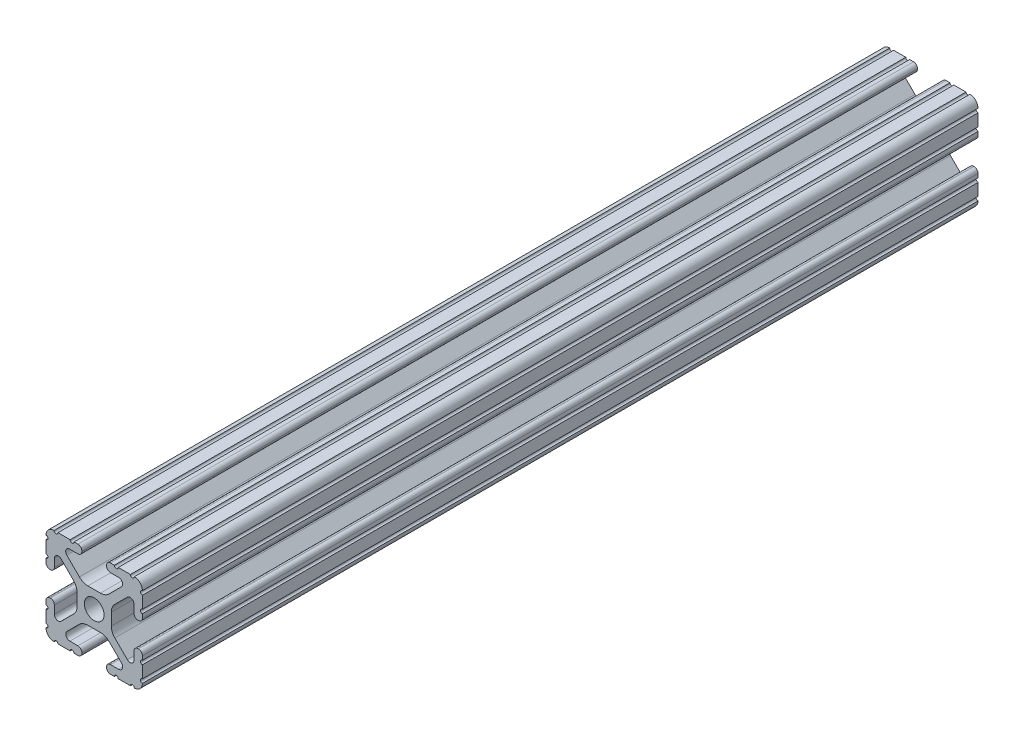
from build123d import *

# Parameters (mm, degrees)
SKETCH1_R               = 2.6035
BOSS_EXTRUDE1_DEPTH     = 304.8
SKETCH2_W               = 393.336915217
SKETCH2_H               = 29.247644192
CUT_EXTRUDE1_DEPTH      = 6.35
CUT_EXTRUDE1_DEPTH_BACK = 29.21


with BuildPart() as part:
    # Sketch1 → Boss-Extrude1 (new body, symmetric)
    with BuildSketch(Plane.XY):
        with BuildLine():
            Line((-7.179650497, -8.645192506), (-3.952270251, -5.423690499))
            ThreePointArc((-3.952270251, -5.423690499), (-2.922936451, -4.736929036), (-1.709253557, -4.4958))
            Line((-1.709253557, -4.4958), (1.709253557, -4.4958))
            ThreePointArc((1.709253557, -4.4958), (2.922936451, -4.736929036), (3.952270251, -5.423690499))
            Line((3.952270251, -5.423690499), (7.179650497, -8.645192506))
            ThreePointArc((7.179650497, -8.645192506), (7.41473083, -9.822813117), (6.416408329, -10.4902))
            Line((6.416408329, -10.4902), (4.287512407, -10.4902))
            ThreePointArc((4.287512407, -10.4902), (3.54574862, -10.79744862), (3.2385, -11.539212407))
            Line((3.2385, -11.539212407), (3.2385, -11.650987593))
            ThreePointArc((3.2385, -11.650987593), (3.54574862, -12.39275138), (4.287512407, -12.7))
            Line((4.287512407, -12.7), (5.317126718, -12.7))
            ThreePointArc((5.317126718, -12.7), (5.825126718, -12.192), (6.333126718, -12.7))
            Line((6.333126718, -12.7), (9.550443118, -12.7))
            ThreePointArc((9.550443118, -12.7), (10.058366869, -12.192000006), (10.566443095, -12.699847501))
            ThreePointArc((10.566443095, -12.699847501), (12.082537762, -12.08250727), (12.699846982, -10.566399977))
            ThreePointArc((12.699846982, -10.566399977), (12.192000006, -10.058323491), (12.7, -9.5504))
            Line((12.7, -9.5504), (12.7, -6.3330836))
            ThreePointArc((12.7, -6.3330836), (12.192, -5.8250836), (12.7, -5.3170836))
            Line((12.7, -5.3170836), (12.7, -4.287469289))
            ThreePointArc((12.7, -4.287469289), (12.39275138, -3.545705502), (11.650987593, -3.238456882))
            Line((11.650987593, -3.238456882), (11.539212407, -3.238456882))
            ThreePointArc((11.539212407, -3.238456882), (10.79744862, -3.545705502), (10.4902, -4.287469289))
            Line((10.4902, -4.287469289), (10.4902, -6.402089023))
            ThreePointArc((10.4902, -6.402089023), (9.856505071, -7.351067942), (8.737131347, -7.129408934))
            Line((8.737131347, -7.129408934), (5.441005833, -3.840816462))
            ThreePointArc((5.441005833, -3.840816462), (4.750877967, -2.809883091), (4.5085, -1.593185507))
            Line((4.5085, -1.593185507), (4.5085, 1.593185507))
            ThreePointArc((4.5085, 1.593185507), (4.750877967, 2.809883091), (5.441005833, 3.840816462))
            Line((5.441005833, 3.840816462), (8.737131347, 7.129408934))
            ThreePointArc((8.737131347, 7.129408934), (9.856505071, 7.351067942), (10.4902, 6.402089023))
            Line((10.4902, 6.402089023), (10.4902, 4.287469289))
            ThreePointArc((10.4902, 4.287469289), (10.79744862, 3.545705502), (11.539212407, 3.238456882))
            Line((11.539212407, 3.238456882), (11.650987593, 3.238456882))
            ThreePointArc((11.650987593, 3.238456882), (12.39275138, 3.545705502), (12.7, 4.287469289))
            Line((12.7, 4.287469289), (12.7, 5.3170836))
            ThreePointArc((12.7, 5.3170836), (12.192, 5.8250836), (12.7, 6.3330836))
            Line((12.7, 6.3330836), (12.7, 9.5504))
            ThreePointArc((12.7, 9.5504), (12.192000006, 10.058323491), (12.699846982, 10.566399977))
            ThreePointArc((12.699846982, 10.566399977), (12.082537762, 12.08250727), (10.566443095, 12.699847501))
            ThreePointArc((10.566443095, 12.699847501), (10.058366869, 12.192000006), (9.550443118, 12.7))
            Line((9.550443118, 12.7), (6.333126718, 12.7))
            ThreePointArc((6.333126718, 12.7), (5.825126718, 12.192), (5.317126718, 12.7))
            Line((5.317126718, 12.7), (4.287512407, 12.7))
            ThreePointArc((4.287512407, 12.7), (3.54574862, 12.39275138), (3.2385, 11.650987593))
            Line((3.2385, 11.650987593), (3.2385, 11.539212407))
            ThreePointArc((3.2385, 11.539212407), (3.54574862, 10.79744862), (4.287512407, 10.4902))
            Line((4.287512407, 10.4902), (6.476788598, 10.4902))
            ThreePointArc((6.476788598, 10.4902), (7.432222385, 9.85140422), (7.207036008, 8.724370562))
            Line((7.207036008, 8.724370562), (3.898272566, 5.423169045))
            ThreePointArc((3.898272566, 5.423169045), (2.869120213, 4.736787962), (1.655778399, 4.4958))
            Line((1.655778399, 4.4958), (-1.655778399, 4.4958))
            ThreePointArc((-1.655778399, 4.4958), (-2.869120213, 4.736787962), (-3.898272566, 5.423169045))
            Line((-3.898272566, 5.423169045), (-7.207036008, 8.724370562))
            ThreePointArc((-7.207036008, 8.724370562), (-7.432222385, 9.85140422), (-6.476788598, 10.4902))
            Line((-6.476788598, 10.4902), (-4.287512407, 10.4902))
            ThreePointArc((-4.287512407, 10.4902), (-3.54574862, 10.79744862), (-3.2385, 11.539212407))
            Line((-3.2385, 11.539212407), (-3.2385, 11.650987593))
            ThreePointArc((-3.2385, 11.650987593), (-3.54574862, 12.39275138), (-4.287512407, 12.7))
            Line((-4.287512407, 12.7), (-5.317126718, 12.7))
            ThreePointArc((-5.317126718, 12.7), (-5.825126718, 12.192), (-6.333126718, 12.7))
            Line((-6.333126718, 12.7), (-9.550443118, 12.7))
            ThreePointArc((-9.550443118, 12.7), (-10.058366869, 12.192000006), (-10.566443095, 12.699847501))
            ThreePointArc((-10.566443095, 12.699847501), (-12.082537762, 12.08250727), (-12.699846982, 10.566399977))
            ThreePointArc((-12.699846982, 10.566399977), (-12.192000006, 10.058323491), (-12.7, 9.5504))
            Line((-12.7, 9.5504), (-12.7, 6.3330836))
            ThreePointArc((-12.7, 6.3330836), (-12.192, 5.8250836), (-12.7, 5.3170836))
            Line((-12.7, 5.3170836), (-12.7, 4.287469289))
            ThreePointArc((-12.7, 4.287469289), (-12.39275138, 3.545705502), (-11.650987593, 3.238456882))
            Line((-11.650987593, 3.238456882), (-11.539212407, 3.238456882))
            ThreePointArc((-11.539212407, 3.238456882), (-10.79744862, 3.545705502), (-10.4902, 4.287469289))
            Line((-10.4902, 4.287469289), (-10.4902, 6.402089023))
            ThreePointArc((-10.4902, 6.402089023), (-9.856505071, 7.351067942), (-8.737131347, 7.129408934))
            Line((-8.737131347, 7.129408934), (-5.441005833, 3.840816462))
            ThreePointArc((-5.441005833, 3.840816462), (-4.750877967, 2.809883091), (-4.5085, 1.593185507))
            Line((-4.5085, 1.593185507), (-4.5085, -1.593185507))
            ThreePointArc((-4.5085, -1.593185507), (-4.750877967, -2.809883091), (-5.441005833, -3.840816462))
            Line((-5.441005833, -3.840816462), (-8.737131347, -7.129408934))
            ThreePointArc((-8.737131347, -7.129408934), (-9.856505071, -7.351067942), (-10.4902, -6.402089023))
            Line((-10.4902, -6.402089023), (-10.4902, -4.287469289))
            ThreePointArc((-10.4902, -4.287469289), (-10.79744862, -3.545705502), (-11.539212407, -3.238456882))
            Line((-11.539212407, -3.238456882), (-11.650987593, -3.238456882))
            ThreePointArc((-11.650987593, -3.238456882), (-12.39275138, -3.545705502), (-12.7, -4.287469289))
            Line((-12.7, -4.287469289), (-12.7, -5.3170836))
            ThreePointArc((-12.7, -5.3170836), (-12.192, -5.8250836), (-12.7, -6.3330836))
            Line((-12.7, -6.3330836), (-12.7, -9.5504))
            ThreePointArc((-12.7, -9.5504), (-12.192000006, -10.058323491), (-12.699846982, -10.566399977))
            ThreePointArc((-12.699846982, -10.566399977), (-12.082537762, -12.08250727), (-10.566443095, -12.699847501))
            ThreePointArc((-10.566443095, -12.699847501), (-10.058366869, -12.192000006), (-9.550443118, -12.7))
            Line((-9.550443118, -12.7), (-6.333126718, -12.7))
            ThreePointArc((-6.333126718, -12.7), (-5.825126718, -12.192), (-5.317126718, -12.7))
            Line((-5.317126718, -12.7), (-4.287512407, -12.7))
            ThreePointArc((-4.287512407, -12.7), (-3.54574862, -12.39275138), (-3.2385, -11.650987593))
            Line((-3.2385, -11.650987593), (-3.2385, -11.539212407))
            ThreePointArc((-3.2385, -11.539212407), (-3.54574862, -10.79744862), (-4.287512407, -10.4902))
            Line((-4.287512407, -10.4902), (-6.416408329, -10.4902))
            ThreePointArc((-6.416408329, -10.4902), (-7.41473083, -9.822813117), (-7.179650497, -8.645192506))
        make_face()
        Circle(SKETCH1_R, mode=Mode.SUBTRACT)
    extrude(amount=BOSS_EXTRUDE1_DEPTH, both=True)

    # Sketch2 → Cut-Extrude1 (cut, two sides)
    with BuildSketch(Plane(origin=(12.7, 0, 0), x_dir=(0, 0, -1), z_dir=(1, 0, 0))) as cut_extrude1_sk:
        with Locations((112.1021859, 0.153496859)):
            Rectangle(SKETCH2_W, SKETCH2_H)
    extrude(amount=CUT_EXTRUDE1_DEPTH, mode=Mode.SUBTRACT)
    extrude(cut_extrude1_sk.sketch, amount=-CUT_EXTRUDE1_DEPTH_BACK, mode=Mode.SUBTRACT)


solid = part.part
